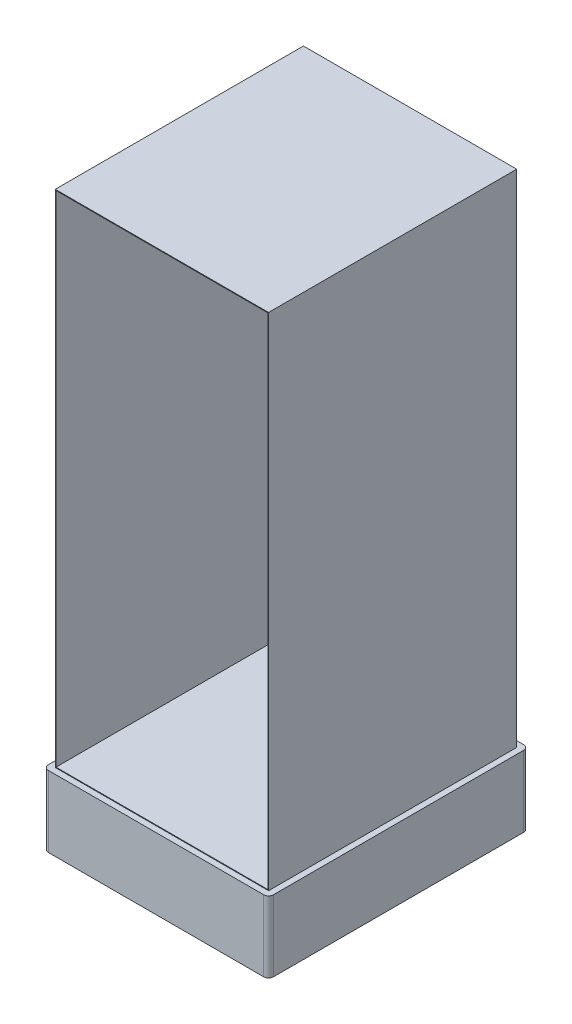
from build123d import *

# Parameters (mm, degrees)
CROQUIS1_W              = 900
CROQUIS1_H              = 1047
SALIENTE_EXTRUIR1_DEPTH = 2113
VACIADO2_T              = -10
CROQUIS2_W              = 880
CROQUIS2_H              = 2093
SALIENTE_EXTRUIR2_DEPTH = 5
SALIENTE_EXTRUIR3_DEPTH = 300
CORTAR_EXTRUIR1_DEPTH   = 1044


with BuildPart() as part:
    # Croquis1 → Saliente-Extruir1 (new body)
    with BuildSketch(Plane(origin=(0, 0, 0), x_dir=(1, 0, 0), z_dir=(0, 1, 0))):
        Rectangle(CROQUIS1_W, CROQUIS1_H)
    extrude(amount=SALIENTE_EXTRUIR1_DEPTH)

    # Vaciado2
    vaciado2_openings = [part.faces().sort_by_distance(p)[0] for p in [
        (0, 1056.5, 523.5),
    ]]
    offset(amount=VACIADO2_T, openings=vaciado2_openings, kind=Kind.INTERSECTION)

    # Croquis2 → Saliente-Extruir2 (add)
    with BuildSketch(Plane.XY.offset(523.5)):
        with Locations((0, 1056.5)):
            Rectangle(CROQUIS2_W, CROQUIS2_H)
    extrude(amount=-SALIENTE_EXTRUIR2_DEPTH)

    # Croquis4 → Saliente-Extruir3 (add)
    with BuildSketch(Plane.XZ):
        with BuildLine():
            Line((-454.35645152, 548.5), (454.35645152, 548.5))
            ThreePointArc((454.35645152, 548.5), (468.953644638, 542.453644638), (475, 527.85645152))
            Line((475, 527.85645152), (475, -527.85645152))
            ThreePointArc((475, -527.85645152), (468.953644638, -542.453644638), (454.35645152, -548.5))
            Line((454.35645152, -548.5), (-454.35645152, -548.5))
            ThreePointArc((-454.35645152, -548.5), (-468.953644638, -542.453644638), (-475, -527.85645152))
            Line((-475, -527.85645152), (-475, 527.85645152))
            ThreePointArc((-475, 527.85645152), (-468.953644638, 542.453644638), (-454.35645152, 548.5))
        make_face()
    extrude(amount=SALIENTE_EXTRUIR3_DEPTH)

    # Croquis5 → Cortar-Extruir1 (cut)
    with BuildSketch(Plane.XY.offset(-513.5)):
        Polygon((-447, 10), (-447, 2110), (447, 2110), (447, 10), (447, 3), (-447, 3), align=None)
    extrude(amount=CORTAR_EXTRUIR1_DEPTH, mode=Mode.SUBTRACT)


solid = part.part
